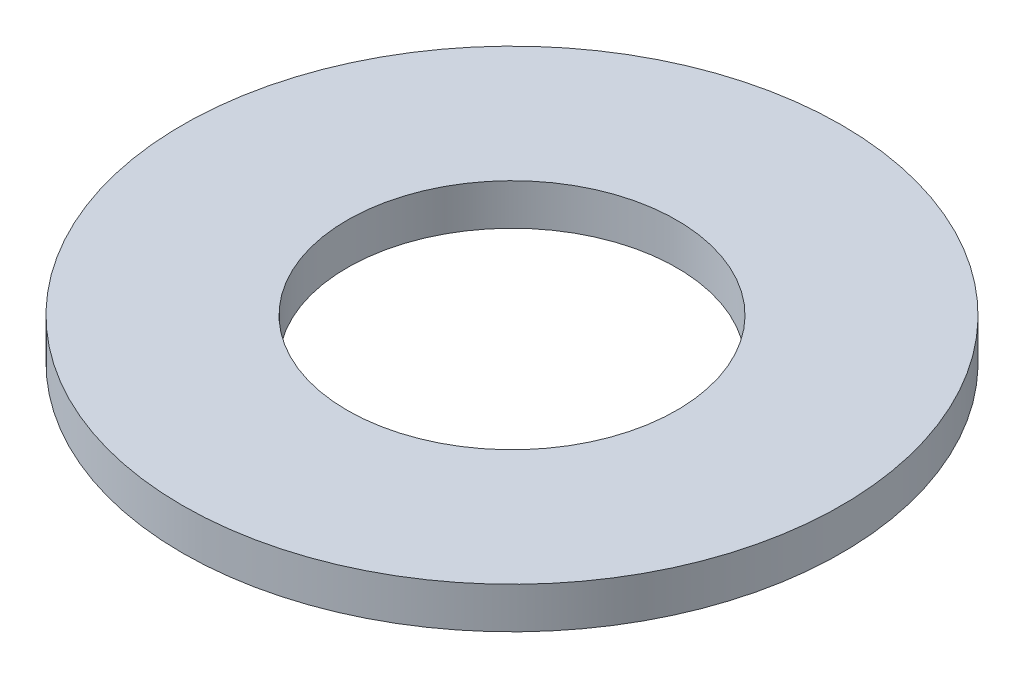
from build123d import *

# Parameters (mm, degrees)
SKETCH1_R      = 8
SKETCH1_R_2    = 4
EXTRUDE1_DEPTH = 1


with BuildPart() as part:
    # Sketch1 → Extrude1 (new body)
    with BuildSketch(Plane(origin=(0, 0, 0), x_dir=(1, 0, 0), z_dir=(0, 1, 0))):
        Circle(SKETCH1_R)
        Circle(SKETCH1_R_2, mode=Mode.SUBTRACT)
    extrude(amount=EXTRUDE1_DEPTH)


solid = part.part
